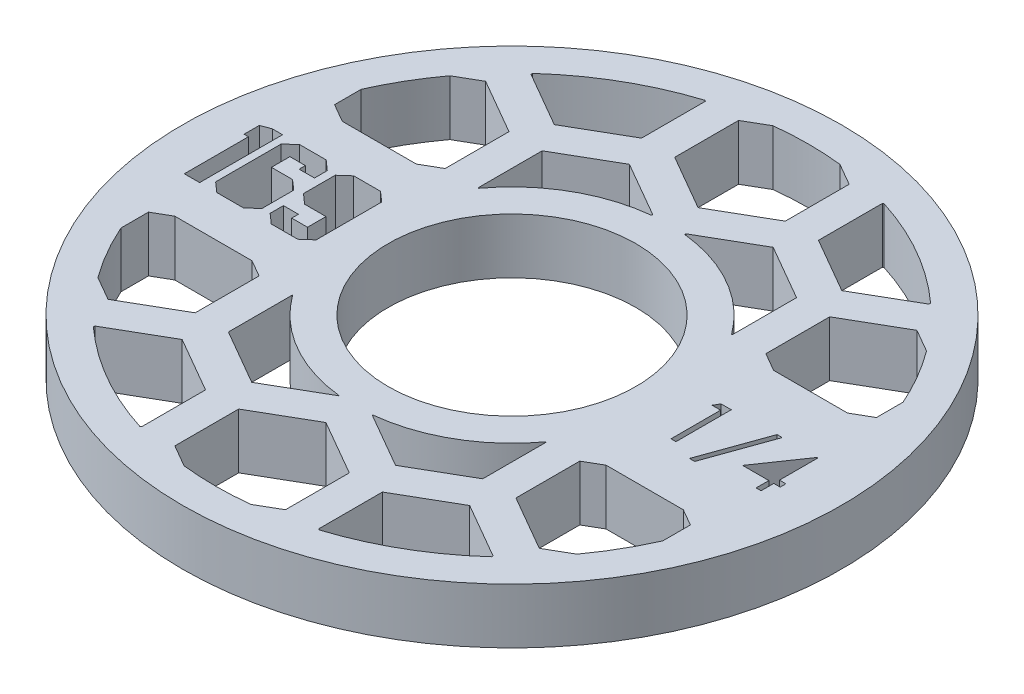
from build123d import *

# Parameters (mm, degrees)
SKETCH1_R               = 37.846
SKETCH1_R_2             = 14.224
BOSS_EXTRUDE1_DEPTH     = 6.35
CUT_EXTRUDE1_DEPTH      = 1
CUT_EXTRUDE1_DEPTH_BACK = 7.35
CUT_EXTRUDE2_DEPTH      = 1
CUT_EXTRUDE2_DEPTH_BACK = 7.35


with BuildPart() as part:
    # Sketch1 → Boss-Extrude1 (new body)
    with BuildSketch(Plane(origin=(0, 0, 0), x_dir=(1, 0, 0), z_dir=(0, 1, 0))):
        Circle(SKETCH1_R)
        Circle(SKETCH1_R_2, mode=Mode.SUBTRACT)
    extrude(amount=BOSS_EXTRUDE1_DEPTH)

    # Sketch2 → Cut-Extrude1 (cut, two sides)
    with BuildSketch(Plane(origin=(0, 6.35, 0), x_dir=(1, 0, 0), z_dir=(0, 1, 0))) as cut_extrude1_sk:
        Polygon((-18.723278008, -3.767243493), (-19.849678423, -4.7625), (-22.882156733, -4.7625), (-24.01035364, -3.767243493), (-24.01035364, -2.234835911), (-22.294703885, -2.234835911), (-22.294703885, -3.00373444), (-20.480247077, -3.00373444), (-20.480247077, -0.882077518), (-22.93605149, -0.882077518), (-24.058858921, 0.113178989), (-24.058858921, 3.761854017), (-22.93605149, 4.7625), (-19.862253866, 4.7625), (-18.723278008, 3.756464542), align=None)
        Polygon((-24.955308374, -3.767243493), (-26.083505281, -4.7625), (-29.139337986, -4.7625), (-30.267534892, -3.767243493), (-30.267534892, 3.761854017), (-29.151913429, 4.7625), (-26.1014702, 4.7625), (-24.973273293, 3.761854017), (-24.973273293, 2.288730668), (-26.737428329, 2.288730668), (-26.737428329, 3.00373444), (-28.508769332, 3.00373444), (-28.508769332, 0.882077518), (-26.083505281, 0.882077518), (-24.955308374, -0.105993022), align=None)
        Polygon((-31.110089589, -4.7625), (-32.868855149, -4.7625), (-32.868855149, 2.597727273), (-33.371872878, 2.597727273), (-33.371872878, 4.356492833), (-32.286791777, 4.7625), (-31.110089589, 4.7625), align=None)
        Polygon((20.831103766, 3.175), (22.005192308, 3.175), (22.005192308, -3.175), (21.435320513, -3.175), (21.435320513, 2.523717949), (20.458397436, 2.523717949), align=None)
        Polygon((27.703910256, 3.337820513), (25.047900641, -4.070512821), (24.4475, -4.070512821), (27.103509615, 3.337820513), align=None)
        Polygon((31.658667869, 3.337820513), (31.774423077, 3.337820513), (31.774423077, -1.058333333), (32.507115385, -1.058333333), (32.507115385, -1.709615385), (31.774423077, -1.709615385), (31.774423077, -3.175), (31.204551282, -3.175), (31.204551282, -1.709615385), (28.192371795, -1.709615385), align=None)
    extrude(amount=CUT_EXTRUDE1_DEPTH, mode=Mode.SUBTRACT)
    extrude(cut_extrude1_sk.sketch, amount=-CUT_EXTRUDE1_DEPTH_BACK, mode=Mode.SUBTRACT)

    # Sketch3 → Cut-Extrude2 (cut, two sides)
    with BuildSketch(Plane(origin=(0, 6.35, 0), x_dir=(1, 0, 0), z_dir=(0, 1, 0))) as cut_extrude2_sk:
        with BuildLine():
            Line((14.605, -10.631905207), (14.578021506, -10.616329166))
            ThreePointArc((14.578021506, -10.616329166), (9.017, -15.617902132), (1.905, -17.933101544))
            Line((1.905, -17.933101544), (1.905, -17.964253626))
            Line((1.905, -17.964253626), (8.255, -21.630427835))
            Line((8.255, -21.630427835), (14.605, -17.964253626))
            Line((14.605, -17.964253626), (14.605, -10.631905207))
        make_face()
        with BuildLine():
            ThreePointArc((-1.905, -17.933101544), (-9.017, -15.617902132), (-14.578021506, -10.616329166))
            Line((-14.578021506, -10.616329166), (-14.605, -10.631905207))
            Line((-14.605, -10.631905207), (-14.605, -17.964253626))
            Line((-14.605, -17.964253626), (-8.255, -21.630427835))
            Line((-8.255, -21.630427835), (-1.905, -17.964253626))
            Line((-1.905, -17.964253626), (-1.905, -17.933101544))
        make_face()
        with BuildLine():
            Line((29.197783942, -9.525), (20.332216058, -9.525))
            Line((20.332216058, -9.525), (18.415, -10.631905207))
            Line((18.415, -10.631905207), (18.415, -17.964253626))
            Line((18.415, -17.964253626), (24.765, -21.630427835))
            Line((24.765, -21.630427835), (27.504447445, -20.048807115))
            ThreePointArc((27.504447445, -20.048807115), (29.476040643, -17.018), (31.115, -13.795146647))
            Line((31.115, -13.795146647), (31.115, -10.631905207))
            Line((31.115, -10.631905207), (29.197783942, -9.525))
        make_face()
        with BuildLine():
            Line((-18.415, -10.631905207), (-20.332216058, -9.525))
            Line((-20.332216058, -9.525), (-29.197783942, -9.525))
            Line((-29.197783942, -9.525), (-31.115, -10.631905207))
            Line((-31.115, -10.631905207), (-31.115, -13.795146647))
            ThreePointArc((-31.115, -13.795146647), (-29.476040643, -17.018), (-27.504447445, -20.048807115))
            Line((-27.504447445, -20.048807115), (-24.765, -21.630427835))
            Line((-24.765, -21.630427835), (-18.415, -17.964253626))
            Line((-18.415, -17.964253626), (-18.415, -10.631905207))
        make_face()
        with BuildLine():
            ThreePointArc((1.905, 17.933101544), (8.977045814, 15.640901651), (14.523553183, 10.690723032))
            Line((14.523553183, 10.690723032), (14.605, 10.737746374))
            Line((14.605, 10.737746374), (14.605, 18.070094793))
            Line((14.605, 18.070094793), (8.255, 21.736269002))
            Line((8.255, 21.736269002), (1.905, 18.070094793))
            Line((1.905, 18.070094793), (1.905, 17.933101544))
        make_face()
        with BuildLine():
            Line((-14.605, 10.737746374), (-14.523553183, 10.690723032))
            ThreePointArc((-14.523553183, 10.690723032), (-8.977045814, 15.640901651), (-1.905, 17.933101544))
            Line((-1.905, 17.933101544), (-1.905, 18.070094793))
            Line((-1.905, 18.070094793), (-8.255, 21.736269002))
            Line((-8.255, 21.736269002), (-14.605, 18.070094793))
            Line((-14.605, 18.070094793), (-14.605, 10.737746374))
        make_face()
        with BuildLine():
            Line((18.415, 10.737746374), (20.515538337, 9.525))
            Line((20.515538337, 9.525), (29.014461663, 9.525))
            Line((29.014461663, 9.525), (31.115, 10.737746374))
            Line((31.115, 10.737746374), (31.115, 13.795146647))
            ThreePointArc((31.115, 13.795146647), (29.418907432, 17.11657622), (27.369604296, 20.232500011))
            Line((27.369604296, 20.232500011), (24.765, 21.736269002))
            Line((24.765, 21.736269002), (18.415, 18.070094793))
            Line((18.415, 18.070094793), (18.415, 10.737746374))
        make_face()
        with BuildLine():
            Line((-29.014461663, 9.525), (-20.515538337, 9.525))
            Line((-20.515538337, 9.525), (-18.415, 10.737746374))
            Line((-18.415, 10.737746374), (-18.415, 18.070094793))
            Line((-18.415, 18.070094793), (-24.765, 21.736269002))
            Line((-24.765, 21.736269002), (-27.369604296, 20.232500011))
            ThreePointArc((-27.369604296, 20.232500011), (-29.418907432, 17.11657622), (-31.115, 13.795146647))
            Line((-31.115, 13.795146647), (-31.115, 10.737746374))
            Line((-31.115, 10.737746374), (-29.014461663, 9.525))
        make_face()
        with BuildLine():
            ThreePointArc((10.290035143, -32.443250034), (16.964310844, -29.506972965), (22.86, -25.216456849))
            Line((22.86, -25.216456849), (22.86, -25.035825791))
            Line((22.86, -25.035825791), (16.51, -21.369651581))
            Line((16.51, -21.369651581), (10.16, -25.035825791))
            Line((10.16, -25.035825791), (10.16, -32.368174209))
            Line((10.16, -32.368174209), (10.290035143, -32.443250034))
        make_face()
        with BuildLine():
            Line((-22.86, -25.035825791), (-22.86, -25.216456849))
            ThreePointArc((-22.86, -25.216456849), (-16.964310844, -29.506972965), (-10.290035143, -32.443250034))
            Line((-10.290035143, -32.443250034), (-10.16, -32.368174209))
            Line((-10.16, -32.368174209), (-10.16, -25.035825791))
            Line((-10.16, -25.035825791), (-16.51, -21.369651581))
            Line((-16.51, -21.369651581), (-22.86, -25.035825791))
        make_face()
        with BuildLine():
            ThreePointArc((-3.837056844, -33.819022617), (0, -34.036), (3.837056844, -33.819022617))
            Line((3.837056844, -33.819022617), (6.35, -32.368174209))
            Line((6.35, -32.368174209), (6.35, -25.035825791))
            Line((6.35, -25.035825791), (0, -21.369651581))
            Line((0, -21.369651581), (-6.35, -25.035825791))
            Line((-6.35, -25.035825791), (-6.35, -32.368174209))
            Line((-6.35, -32.368174209), (-3.837056844, -33.819022617))
        make_face()
        with BuildLine():
            Line((22.86, 25.035825791), (22.86, 25.216456849))
            ThreePointArc((22.86, 25.216456849), (16.964310844, 29.506972965), (10.290035143, 32.443250034))
            Line((10.290035143, 32.443250034), (10.16, 32.368174209))
            Line((10.16, 32.368174209), (10.16, 25.035825791))
            Line((10.16, 25.035825791), (16.51, 21.369651581))
            Line((16.51, 21.369651581), (22.86, 25.035825791))
        make_face()
        with BuildLine():
            ThreePointArc((-10.290035143, 32.443250034), (-16.964310844, 29.506972965), (-22.86, 25.216456849))
            Line((-22.86, 25.216456849), (-22.86, 25.035825791))
            Line((-22.86, 25.035825791), (-16.51, 21.369651581))
            Line((-16.51, 21.369651581), (-10.16, 25.035825791))
            Line((-10.16, 25.035825791), (-10.16, 32.368174209))
            Line((-10.16, 32.368174209), (-10.290035143, 32.443250034))
        make_face()
        with BuildLine():
            Line((6.35, 32.368174209), (3.837056844, 33.819022617))
            ThreePointArc((3.837056844, 33.819022617), (0, 34.036), (-3.837056844, 33.819022617))
            Line((-3.837056844, 33.819022617), (-6.35, 32.368174209))
            Line((-6.35, 32.368174209), (-6.35, 25.035825791))
            Line((-6.35, 25.035825791), (0, 21.369651581))
            Line((0, 21.369651581), (6.35, 25.035825791))
            Line((6.35, 25.035825791), (6.35, 32.368174209))
        make_face()
    extrude(amount=CUT_EXTRUDE2_DEPTH, mode=Mode.SUBTRACT)
    extrude(cut_extrude2_sk.sketch, amount=-CUT_EXTRUDE2_DEPTH_BACK, mode=Mode.SUBTRACT)


solid = part.part
